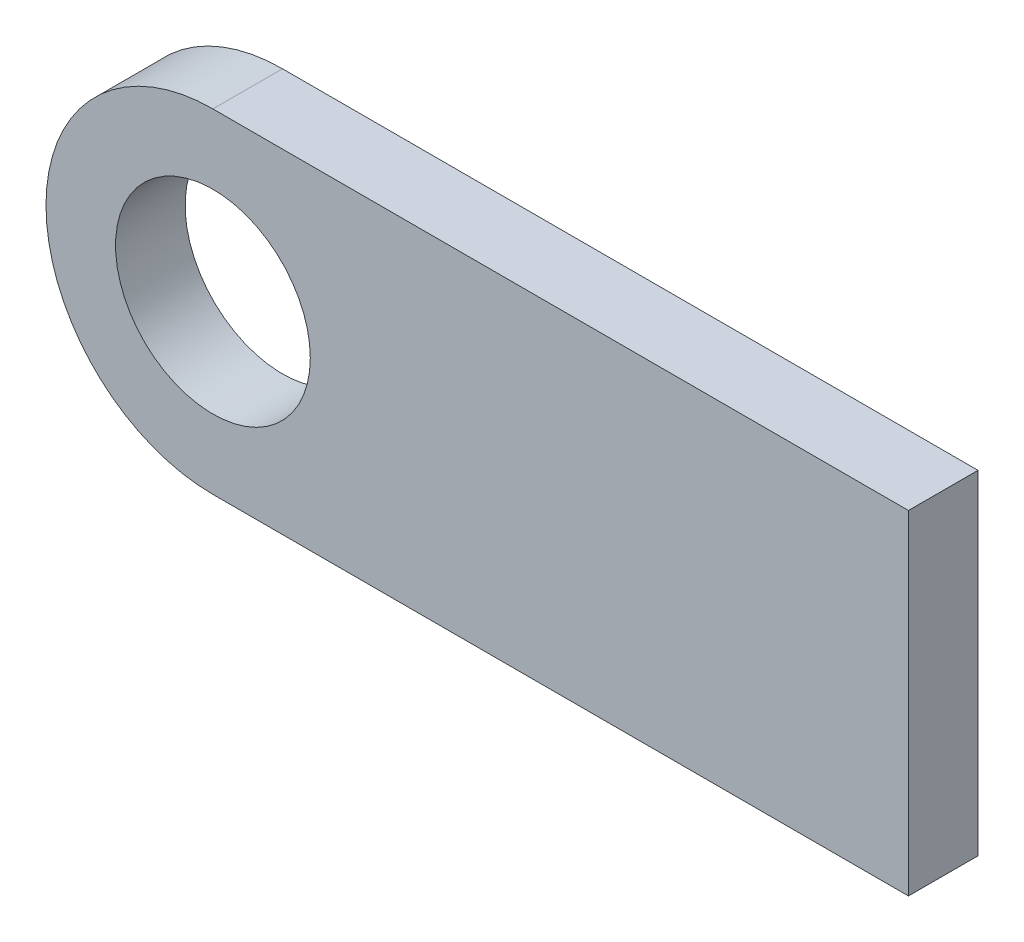
from build123d import *

# Parameters (mm, degrees)
SZKIC1_R                    = 7
DODANIE_WYCI_GNI_CIE1_DEPTH = 5


with BuildPart() as part:
    # Szkic1 → Dodanie-wyciągnięcie1 (new body)
    with BuildSketch(Plane.XY):
        with BuildLine():
            Line((0, 0), (50, 0))
            Line((50, 0), (50, 24))
            Line((50, 24), (0, 24))
            ThreePointArc((0, 24), (-12, 12), (0, 0))
        make_face()
        with Locations((0, 12)):
            Circle(SZKIC1_R, mode=Mode.SUBTRACT)
    extrude(amount=DODANIE_WYCI_GNI_CIE1_DEPTH)


solid = part.part
